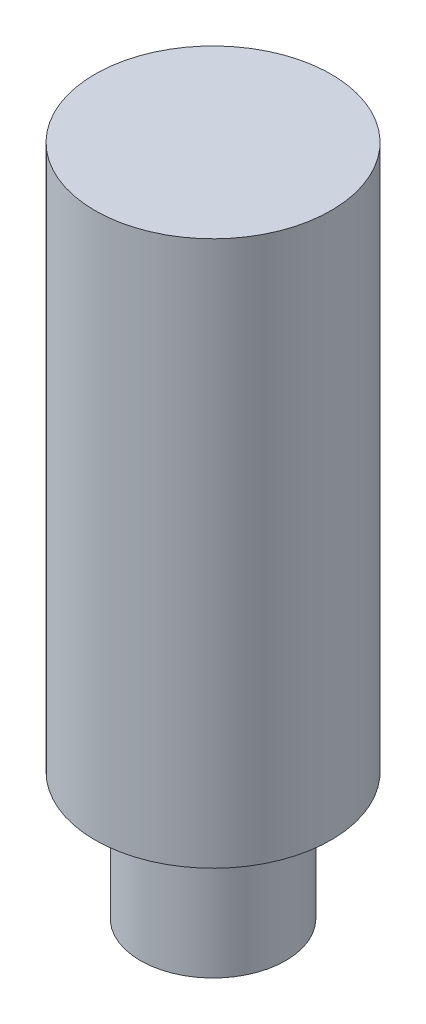
from build123d import *

# Parameters (mm, degrees)
SKETCH1_R           = 4
BOSS_EXTRUDE1_DEPTH = 3.5
SKETCH2_R           = 6.5
BOSS_EXTRUDE2_DEPTH = 30


with BuildPart() as part:
    # Sketch1 → Boss-Extrude1 (new body, symmetric)
    with BuildSketch(Plane(origin=(0, 0, 0), x_dir=(1, 0, 0), z_dir=(0, 1, 0))):
        Circle(SKETCH1_R)
    extrude(amount=BOSS_EXTRUDE1_DEPTH, both=True)

    # Sketch2 → Boss-Extrude2 (add)
    with BuildSketch(Plane(origin=(0, 3.5, 0), x_dir=(1, 0, 0), z_dir=(0, 1, 0))):
        Circle(SKETCH2_R)
    extrude(amount=BOSS_EXTRUDE2_DEPTH)


solid = part.part
